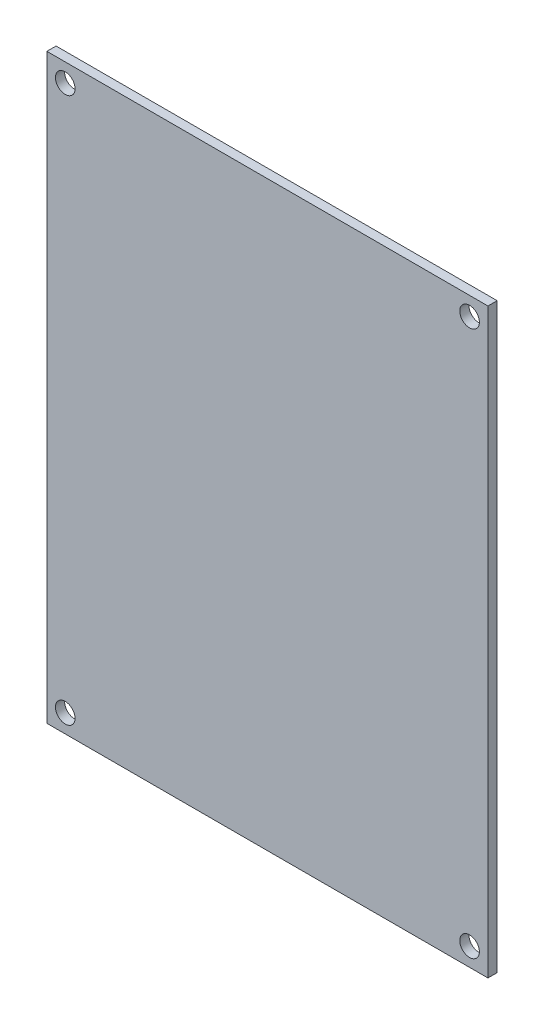
from build123d import *

# Parameters (mm, degrees)
SKETCH_1_W      = 72
SKETCH_1_H      = 95
SKETCH_1_R      = 1.6
EXTRUDE_1_DEPTH = 1.5


with BuildPart() as part:
    # ｽｹｯﾁ1 → ﾎﾞｽ - 押し出し1 (new body)
    with BuildSketch(Plane.XY):
        Rectangle(SKETCH_1_W, SKETCH_1_H)
        with Locations((-33, 44.5)):
            Circle(SKETCH_1_R, mode=Mode.SUBTRACT)
        with Locations((33, 44.5)):
            Circle(SKETCH_1_R, mode=Mode.SUBTRACT)
        with Locations((-33, -44.5)):
            Circle(SKETCH_1_R, mode=Mode.SUBTRACT)
        with Locations((33, -44.5)):
            Circle(SKETCH_1_R, mode=Mode.SUBTRACT)
    extrude(amount=EXTRUDE_1_DEPTH)


solid = part.part
